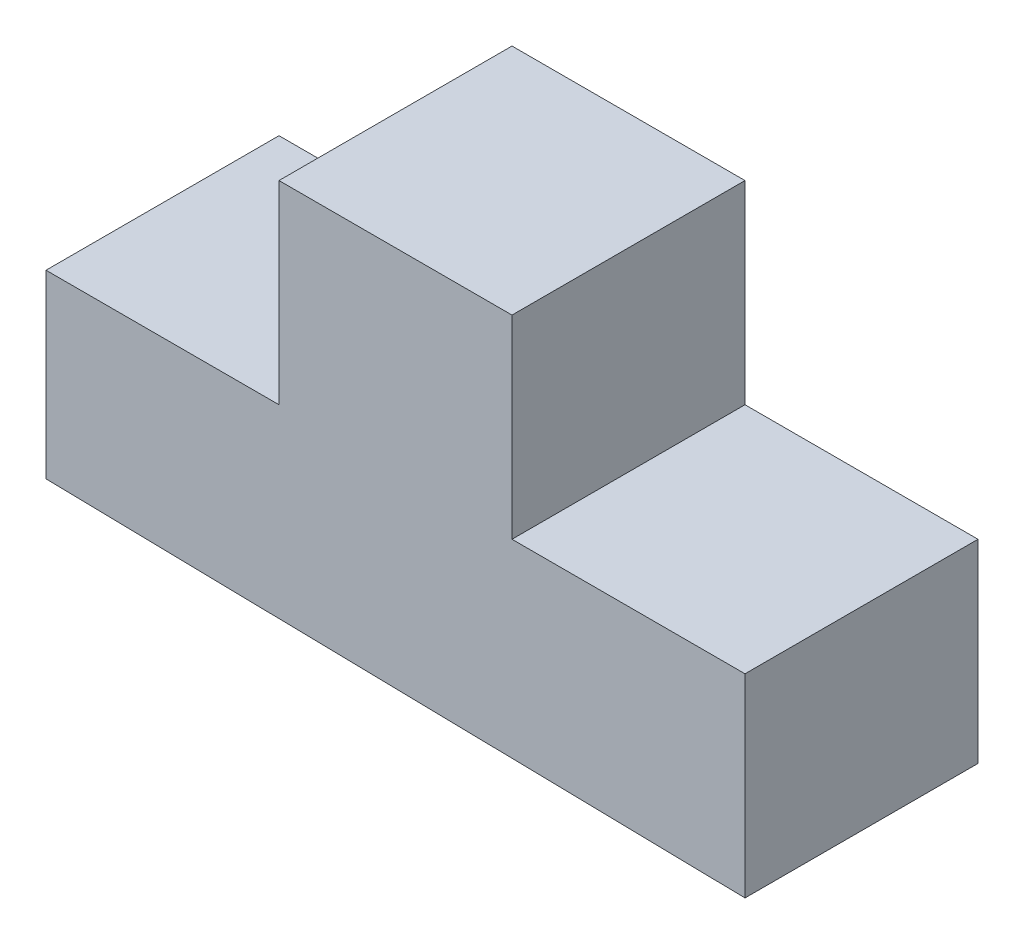
from build123d import *

# Parameters (mm, degrees)
BOSS_EXTRUDE1_DEPTH = 30


with BuildPart() as part:
    # Sketch1 → Boss-Extrude1 (new body)
    with BuildSketch(Plane.XY):
        Polygon((0, 0), (90, -1.730661323), (90, 23.269338677), (60, 23.269338677), (60, 48.269338677), (30, 48.269338677), (30, 23.269338677), (0, 23.269338677), align=None)
    extrude(amount=BOSS_EXTRUDE1_DEPTH)


solid = part.part
